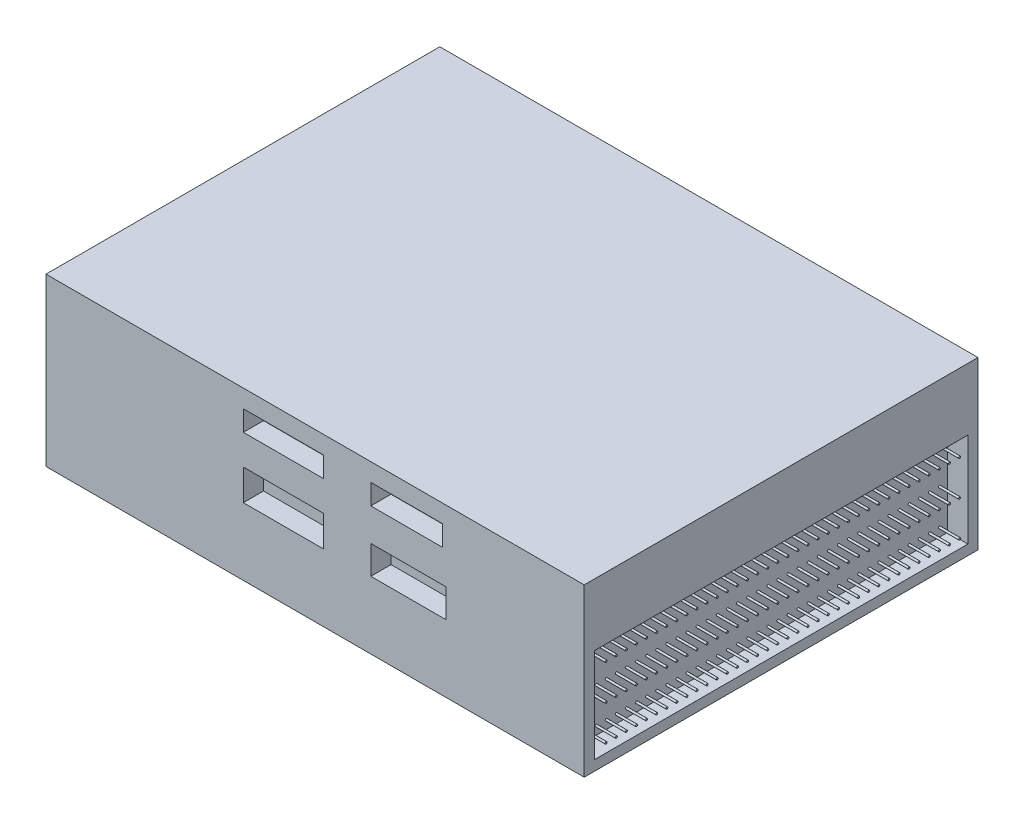
from build123d import *

# Parameters (mm, degrees)
SKETCH1_W           = 53.3
SKETCH1_H           = 39
BOSS_EXTRUDE1_DEPTH = 16.5
SKETCH2_W           = 37
SKETCH2_H           = 9.350176664
SKETCH2_R           = 0.1
CUT_EXTRUDE1_DEPTH  = 2
SKETCH3_W           = 6.767712535
SKETCH3_H           = 2.174962724
SKETCH3_W_2         = 9.468988353
SKETCH3_H_2         = 2.933643631
SKETCH3_W_3         = 9.870984668
SKETCH3_W_4         = 11.209423267
SKETCH3_W_5         = 11.167597061
CUT_EXTRUDE2_DEPTH  = 2
SKETCH4_W           = 6.629260047
SKETCH4_H           = 2.183289237
SKETCH4_W_2         = 7.820145085
CUT_EXTRUDE3_DEPTH  = 2
SKETCH5_W           = 7.939233588
SKETCH5_H           = 2.024504565
SKETCH5_H_2         = 3.056604931
SKETCH5_W_2         = 7.105614061
SKETCH5_W_3         = 7.423183405
SKETCH5_H_3         = 2.818427924
CUT_EXTRUDE4_DEPTH  = 2


with BuildPart() as part:
    # Sketch1 → Boss-Extrude1 (new body)
    with BuildSketch(Plane(origin=(0, 0, 0), x_dir=(1, 0, 0), z_dir=(0, 1, 0))):
        Rectangle(SKETCH1_W, SKETCH1_H)
    extrude(amount=BOSS_EXTRUDE1_DEPTH)

    # Sketch2 → Cut-Extrude1 (cut)
    with BuildSketch(Plane(origin=(26.65, 0, 0), x_dir=(0, 0, -1), z_dir=(1, 0, 0))):
        with Locations((0, 5.675088332)):
            Rectangle(SKETCH2_W, SKETCH2_H)
        with Locations((-17.319426035, 8.850176664)):
            Circle(SKETCH2_R, mode=Mode.SUBTRACT)
        with Locations((-17.319426035, 5.350176664)):
            Circle(SKETCH2_R, mode=Mode.SUBTRACT)
        with Locations((-17.319426035, 1.850176664)):
            Circle(SKETCH2_R, mode=Mode.SUBTRACT)
        with Locations((-16.319426035, 8.850176664)):
            Circle(SKETCH2_R, mode=Mode.SUBTRACT)
        with Locations((-16.319426035, 5.350176664)):
            Circle(SKETCH2_R, mode=Mode.SUBTRACT)
        with Locations((-16.319426035, 1.850176664)):
            Circle(SKETCH2_R, mode=Mode.SUBTRACT)
        with Locations((-15.319426035, 8.850176664)):
            Circle(SKETCH2_R, mode=Mode.SUBTRACT)
        with Locations((-15.319426035, 5.350176664)):
            Circle(SKETCH2_R, mode=Mode.SUBTRACT)
        with Locations((-15.319426035, 1.850176664)):
            Circle(SKETCH2_R, mode=Mode.SUBTRACT)
        with Locations((-14.319426035, 8.850176664)):
            Circle(SKETCH2_R, mode=Mode.SUBTRACT)
        with Locations((-14.319426035, 5.350176664)):
            Circle(SKETCH2_R, mode=Mode.SUBTRACT)
        with Locations((-14.319426035, 1.850176664)):
            Circle(SKETCH2_R, mode=Mode.SUBTRACT)
        with Locations((-13.319426035, 8.850176664)):
            Circle(SKETCH2_R, mode=Mode.SUBTRACT)
        with Locations((-13.319426035, 5.350176664)):
            Circle(SKETCH2_R, mode=Mode.SUBTRACT)
        with Locations((-13.319426035, 1.850176664)):
            Circle(SKETCH2_R, mode=Mode.SUBTRACT)
        with Locations((-12.319426035, 8.850176664)):
            Circle(SKETCH2_R, mode=Mode.SUBTRACT)
        with Locations((-12.319426035, 5.350176664)):
            Circle(SKETCH2_R, mode=Mode.SUBTRACT)
        with Locations((-12.319426035, 1.850176664)):
            Circle(SKETCH2_R, mode=Mode.SUBTRACT)
        with Locations((-11.319426035, 8.850176664)):
            Circle(SKETCH2_R, mode=Mode.SUBTRACT)
        with Locations((-11.319426035, 5.350176664)):
            Circle(SKETCH2_R, mode=Mode.SUBTRACT)
        with Locations((-11.319426035, 1.850176664)):
            Circle(SKETCH2_R, mode=Mode.SUBTRACT)
        with Locations((-10.319426035, 8.850176664)):
            Circle(SKETCH2_R, mode=Mode.SUBTRACT)
        with Locations((-10.319426035, 5.350176664)):
            Circle(SKETCH2_R, mode=Mode.SUBTRACT)
        with Locations((-10.319426035, 1.850176664)):
            Circle(SKETCH2_R, mode=Mode.SUBTRACT)
        with Locations((-9.319426035, 8.850176664)):
            Circle(SKETCH2_R, mode=Mode.SUBTRACT)
        with Locations((-9.319426035, 5.350176664)):
            Circle(SKETCH2_R, mode=Mode.SUBTRACT)
        with Locations((-9.319426035, 1.850176664)):
            Circle(SKETCH2_R, mode=Mode.SUBTRACT)
        with Locations((-8.319426035, 8.850176664)):
            Circle(SKETCH2_R, mode=Mode.SUBTRACT)
        with Locations((-8.319426035, 5.350176664)):
            Circle(SKETCH2_R, mode=Mode.SUBTRACT)
        with Locations((-8.319426035, 1.850176664)):
            Circle(SKETCH2_R, mode=Mode.SUBTRACT)
        with Locations((-7.319426035, 8.850176664)):
            Circle(SKETCH2_R, mode=Mode.SUBTRACT)
        with Locations((-7.319426035, 5.350176664)):
            Circle(SKETCH2_R, mode=Mode.SUBTRACT)
        with Locations((-7.319426035, 1.850176664)):
            Circle(SKETCH2_R, mode=Mode.SUBTRACT)
        with Locations((-6.319426035, 8.850176664)):
            Circle(SKETCH2_R, mode=Mode.SUBTRACT)
        with Locations((-6.319426035, 5.350176664)):
            Circle(SKETCH2_R, mode=Mode.SUBTRACT)
        with Locations((-6.319426035, 1.850176664)):
            Circle(SKETCH2_R, mode=Mode.SUBTRACT)
        with Locations((-5.319426035, 8.850176664)):
            Circle(SKETCH2_R, mode=Mode.SUBTRACT)
        with Locations((-5.319426035, 5.350176664)):
            Circle(SKETCH2_R, mode=Mode.SUBTRACT)
        with Locations((-5.319426035, 1.850176664)):
            Circle(SKETCH2_R, mode=Mode.SUBTRACT)
        with Locations((-4.319426035, 8.850176664)):
            Circle(SKETCH2_R, mode=Mode.SUBTRACT)
        with Locations((-4.319426035, 5.350176664)):
            Circle(SKETCH2_R, mode=Mode.SUBTRACT)
        with Locations((-4.319426035, 1.850176664)):
            Circle(SKETCH2_R, mode=Mode.SUBTRACT)
        with Locations((-3.319426035, 8.850176664)):
            Circle(SKETCH2_R, mode=Mode.SUBTRACT)
        with Locations((-3.319426035, 5.350176664)):
            Circle(SKETCH2_R, mode=Mode.SUBTRACT)
        with Locations((-3.319426035, 1.850176664)):
            Circle(SKETCH2_R, mode=Mode.SUBTRACT)
        with Locations((-2.319426035, 8.850176664)):
            Circle(SKETCH2_R, mode=Mode.SUBTRACT)
        with Locations((-2.319426035, 5.350176664)):
            Circle(SKETCH2_R, mode=Mode.SUBTRACT)
        with Locations((-2.319426035, 1.850176664)):
            Circle(SKETCH2_R, mode=Mode.SUBTRACT)
        with Locations((-1.319426035, 8.850176664)):
            Circle(SKETCH2_R, mode=Mode.SUBTRACT)
        with Locations((-1.319426035, 5.350176664)):
            Circle(SKETCH2_R, mode=Mode.SUBTRACT)
        with Locations((-1.319426035, 1.850176664)):
            Circle(SKETCH2_R, mode=Mode.SUBTRACT)
        with Locations((-0.319426035, 8.850176664)):
            Circle(SKETCH2_R, mode=Mode.SUBTRACT)
        with Locations((-0.319426035, 5.350176664)):
            Circle(SKETCH2_R, mode=Mode.SUBTRACT)
        with Locations((-0.319426035, 1.850176664)):
            Circle(SKETCH2_R, mode=Mode.SUBTRACT)
        with Locations((0.680573965, 8.850176664)):
            Circle(SKETCH2_R, mode=Mode.SUBTRACT)
        with Locations((0.680573965, 5.350176664)):
            Circle(SKETCH2_R, mode=Mode.SUBTRACT)
        with Locations((0.680573965, 1.850176664)):
            Circle(SKETCH2_R, mode=Mode.SUBTRACT)
        with Locations((1.680573965, 8.850176664)):
            Circle(SKETCH2_R, mode=Mode.SUBTRACT)
        with Locations((1.680573965, 5.350176664)):
            Circle(SKETCH2_R, mode=Mode.SUBTRACT)
        with Locations((1.680573965, 1.850176664)):
            Circle(SKETCH2_R, mode=Mode.SUBTRACT)
        with Locations((2.680573965, 8.850176664)):
            Circle(SKETCH2_R, mode=Mode.SUBTRACT)
        with Locations((2.680573965, 5.350176664)):
            Circle(SKETCH2_R, mode=Mode.SUBTRACT)
        with Locations((2.680573965, 1.850176664)):
            Circle(SKETCH2_R, mode=Mode.SUBTRACT)
        with Locations((3.680573965, 8.850176664)):
            Circle(SKETCH2_R, mode=Mode.SUBTRACT)
        with Locations((3.680573965, 5.350176664)):
            Circle(SKETCH2_R, mode=Mode.SUBTRACT)
        with Locations((3.680573965, 1.850176664)):
            Circle(SKETCH2_R, mode=Mode.SUBTRACT)
        with Locations((4.680573965, 8.850176664)):
            Circle(SKETCH2_R, mode=Mode.SUBTRACT)
        with Locations((4.680573965, 5.350176664)):
            Circle(SKETCH2_R, mode=Mode.SUBTRACT)
        with Locations((4.680573965, 1.850176664)):
            Circle(SKETCH2_R, mode=Mode.SUBTRACT)
        with Locations((5.680573965, 8.850176664)):
            Circle(SKETCH2_R, mode=Mode.SUBTRACT)
        with Locations((5.680573965, 5.350176664)):
            Circle(SKETCH2_R, mode=Mode.SUBTRACT)
        with Locations((5.680573965, 1.850176664)):
            Circle(SKETCH2_R, mode=Mode.SUBTRACT)
        with Locations((6.680573965, 8.850176664)):
            Circle(SKETCH2_R, mode=Mode.SUBTRACT)
        with Locations((6.680573965, 5.350176664)):
            Circle(SKETCH2_R, mode=Mode.SUBTRACT)
        with Locations((6.680573965, 1.850176664)):
            Circle(SKETCH2_R, mode=Mode.SUBTRACT)
        with Locations((7.680573965, 8.850176664)):
            Circle(SKETCH2_R, mode=Mode.SUBTRACT)
        with Locations((7.680573965, 5.350176664)):
            Circle(SKETCH2_R, mode=Mode.SUBTRACT)
        with Locations((7.680573965, 1.850176664)):
            Circle(SKETCH2_R, mode=Mode.SUBTRACT)
        with Locations((8.680573965, 8.850176664)):
            Circle(SKETCH2_R, mode=Mode.SUBTRACT)
        with Locations((8.680573965, 5.350176664)):
            Circle(SKETCH2_R, mode=Mode.SUBTRACT)
        with Locations((8.680573965, 1.850176664)):
            Circle(SKETCH2_R, mode=Mode.SUBTRACT)
        with Locations((9.680573965, 8.850176664)):
            Circle(SKETCH2_R, mode=Mode.SUBTRACT)
        with Locations((9.680573965, 5.350176664)):
            Circle(SKETCH2_R, mode=Mode.SUBTRACT)
        with Locations((9.680573965, 1.850176664)):
            Circle(SKETCH2_R, mode=Mode.SUBTRACT)
        with Locations((10.680573965, 8.850176664)):
            Circle(SKETCH2_R, mode=Mode.SUBTRACT)
        with Locations((10.680573965, 5.350176664)):
            Circle(SKETCH2_R, mode=Mode.SUBTRACT)
        with Locations((10.680573965, 1.850176664)):
            Circle(SKETCH2_R, mode=Mode.SUBTRACT)
        with Locations((11.680573965, 8.850176664)):
            Circle(SKETCH2_R, mode=Mode.SUBTRACT)
        with Locations((11.680573965, 5.350176664)):
            Circle(SKETCH2_R, mode=Mode.SUBTRACT)
        with Locations((11.680573965, 1.850176664)):
            Circle(SKETCH2_R, mode=Mode.SUBTRACT)
        with Locations((12.680573965, 8.850176664)):
            Circle(SKETCH2_R, mode=Mode.SUBTRACT)
        with Locations((12.680573965, 5.350176664)):
            Circle(SKETCH2_R, mode=Mode.SUBTRACT)
        with Locations((12.680573965, 1.850176664)):
            Circle(SKETCH2_R, mode=Mode.SUBTRACT)
        with Locations((13.680573965, 8.850176664)):
            Circle(SKETCH2_R, mode=Mode.SUBTRACT)
        with Locations((13.680573965, 5.350176664)):
            Circle(SKETCH2_R, mode=Mode.SUBTRACT)
        with Locations((13.680573965, 1.850176664)):
            Circle(SKETCH2_R, mode=Mode.SUBTRACT)
        with Locations((14.680573965, 8.850176664)):
            Circle(SKETCH2_R, mode=Mode.SUBTRACT)
        with Locations((14.680573965, 5.350176664)):
            Circle(SKETCH2_R, mode=Mode.SUBTRACT)
        with Locations((14.680573965, 1.850176664)):
            Circle(SKETCH2_R, mode=Mode.SUBTRACT)
        with Locations((15.680573965, 8.850176664)):
            Circle(SKETCH2_R, mode=Mode.SUBTRACT)
        with Locations((15.680573965, 5.350176664)):
            Circle(SKETCH2_R, mode=Mode.SUBTRACT)
        with Locations((15.680573965, 1.850176664)):
            Circle(SKETCH2_R, mode=Mode.SUBTRACT)
        with Locations((16.680573965, 8.850176664)):
            Circle(SKETCH2_R, mode=Mode.SUBTRACT)
        with Locations((16.680573965, 5.350176664)):
            Circle(SKETCH2_R, mode=Mode.SUBTRACT)
        with Locations((16.680573965, 1.850176664)):
            Circle(SKETCH2_R, mode=Mode.SUBTRACT)
        with Locations((17.680573965, 8.850176664)):
            Circle(SKETCH2_R, mode=Mode.SUBTRACT)
        with Locations((17.680573965, 5.350176664)):
            Circle(SKETCH2_R, mode=Mode.SUBTRACT)
        with Locations((17.680573965, 1.850176664)):
            Circle(SKETCH2_R, mode=Mode.SUBTRACT)
    extrude(amount=-CUT_EXTRUDE1_DEPTH, mode=Mode.SUBTRACT)

    # Sketch3 → Cut-Extrude2 (cut)
    with BuildSketch(Plane.ZY.offset(26.65)):
        with Locations((-13.520902081, 8.018117221)):
            Rectangle(SKETCH3_W, SKETCH3_H)
        with Locations((-12.170264172, 4.258406018)):
            Rectangle(SKETCH3_W_2, SKETCH3_H_2)
        with Locations((-0.920176537, 8.018117221)):
            Rectangle(SKETCH3_W_3, SKETCH3_H)
        with Locations((12.255078423, 8.018117221)):
            Rectangle(SKETCH3_W_4, SKETCH3_H)
        with Locations((-0.920176537, 4.258406018)):
            Rectangle(SKETCH3_W_3, SKETCH3_H_2)
        with Locations((12.275991526, 4.258406018)):
            Rectangle(SKETCH3_W_5, SKETCH3_H_2)
    extrude(amount=-CUT_EXTRUDE2_DEPTH, mode=Mode.SUBTRACT)

    # Sketch4 → Cut-Extrude3 (cut)
    with BuildSketch(Plane(origin=(0, 0, -19.5), x_dir=(-1, 0, 0), z_dir=(0, 0, -1))):
        with Locations((1.687087138, 14.050248623)):
            Rectangle(SKETCH4_W, SKETCH4_H)
        with Locations((15.858619092, 14.050248623)):
            Rectangle(SKETCH4_W_2, SKETCH4_H)
    extrude(amount=-CUT_EXTRUDE3_DEPTH, mode=Mode.SUBTRACT)

    # Sketch5 → Cut-Extrude4 (cut)
    with BuildSketch(Plane.XY.offset(19.5)):
        with Locations((-3.135997267, 13.715948879)):
            Rectangle(SKETCH5_W, SKETCH5_H)
        with Locations((-3.135997267, 8.198181535)):
            Rectangle(SKETCH5_W, SKETCH5_H_2)
        with Locations((9.070574374, 13.715948879)):
            Rectangle(SKETCH5_W_2, SKETCH5_H)
        with Locations((9.229359047, 8.079093031)):
            Rectangle(SKETCH5_W_3, SKETCH5_H_3)
    extrude(amount=-CUT_EXTRUDE4_DEPTH, mode=Mode.SUBTRACT)


solid = part.part
